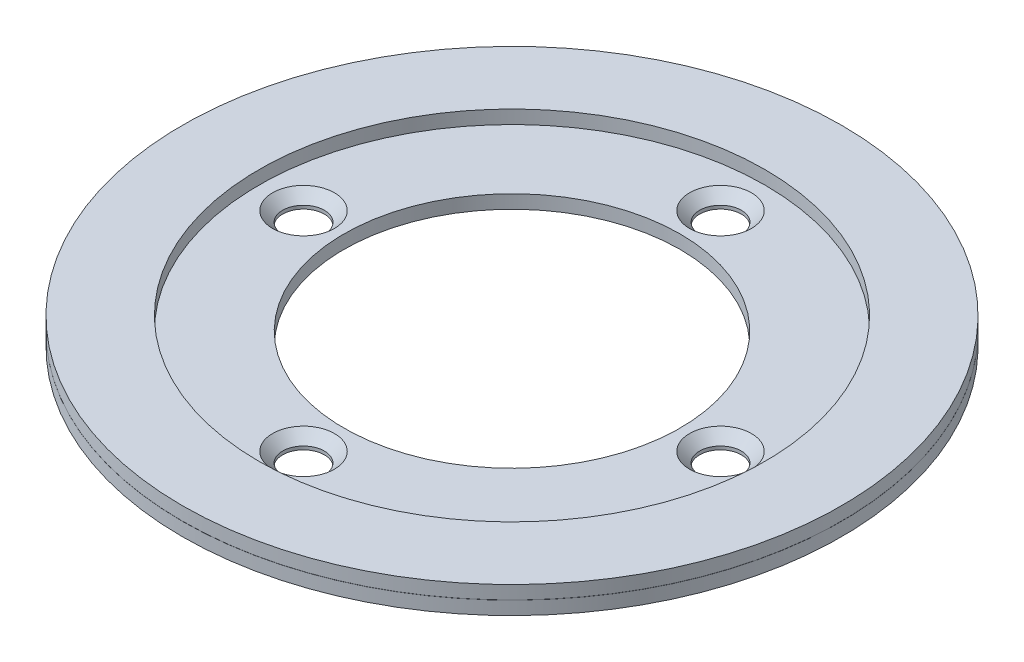
from build123d import *

# Parameters (mm, degrees)
CSK_FOR_M2_5_COUNTERSUNK_FLAT_HEAD_S_2_COUNT = 2
CSK_FOR_M2_5_COUNTERSUNK_FLAT_HEAD_S_2_PITCH = 21.920310217
CSK_FOR_M2_5_COUNTERSUNK_FLAT_HEAD_S_3_COUNT = 2
CSK_FOR_M2_5_COUNTERSUNK_FLAT_HEAD_S_3_PITCH = 31
CSK_FOR_M2_5_COUNTERSUNK_FLAT_HEAD_S_4_COUNT = 2
CSK_FOR_M2_5_COUNTERSUNK_FLAT_HEAD_S_4_PITCH = 21.920310217


with BuildPart() as part:
    # Sketch1 → Revolve1 (revolve)
    with BuildSketch(Plane.XY):
        Polygon((-24.5, 0), (-12.5, 0), (-12.5, 1), (-18.8, 1), (-18.8, 2), (-24.5, 2), (-24.5, 1.005), (-24, 1.005), (-24, 0.995), (-24.5, 0.995), align=None)
    revolve(axis=Axis((0, 0, 0), (0, 1, 0)))

    # Sketch2 → CSK for M2.5 Countersunk Flat Head Screw1 (revolve, cut)
    with BuildSketch(Plane(origin=(0, 1, -15.5), x_dir=(0, 0, 1), z_dir=(1, 0, 0))):
        Polygon((0, 0), (0, 1), (1.55, 1), (1.55, 0.75), (2.3, 0), align=None)
    csk_for_m2_5_countersunk_flat_head_screw = revolve(axis=Axis((0, 7.35, -15.5), (0, -1, 0)), mode=Mode.SUBTRACT)

    # CSK for M2.5 Countersunk Flat Head S 2: CSK for M2.5 Countersunk Flat Head Screw1 ×2
    with Locations(*[Vector(-0.707106781, 0, 0.707106781) * (i * CSK_FOR_M2_5_COUNTERSUNK_FLAT_HEAD_S_2_PITCH) for i in range(1, CSK_FOR_M2_5_COUNTERSUNK_FLAT_HEAD_S_2_COUNT)]):
        add(csk_for_m2_5_countersunk_flat_head_screw, mode=Mode.SUBTRACT)

    # CSK for M2.5 Countersunk Flat Head S 3: CSK for M2.5 Countersunk Flat Head Screw1 ×2
    with Locations(*[(0, 0, i * CSK_FOR_M2_5_COUNTERSUNK_FLAT_HEAD_S_3_PITCH) for i in range(1, CSK_FOR_M2_5_COUNTERSUNK_FLAT_HEAD_S_3_COUNT)]):
        add(csk_for_m2_5_countersunk_flat_head_screw, mode=Mode.SUBTRACT)

    # CSK for M2.5 Countersunk Flat Head S 4: CSK for M2.5 Countersunk Flat Head Screw1 ×2
    with Locations(*[Vector(0.707106781, 0, 0.707106781) * (i * CSK_FOR_M2_5_COUNTERSUNK_FLAT_HEAD_S_4_PITCH) for i in range(1, CSK_FOR_M2_5_COUNTERSUNK_FLAT_HEAD_S_4_COUNT)]):
        add(csk_for_m2_5_countersunk_flat_head_screw, mode=Mode.SUBTRACT)


solid = part.part
